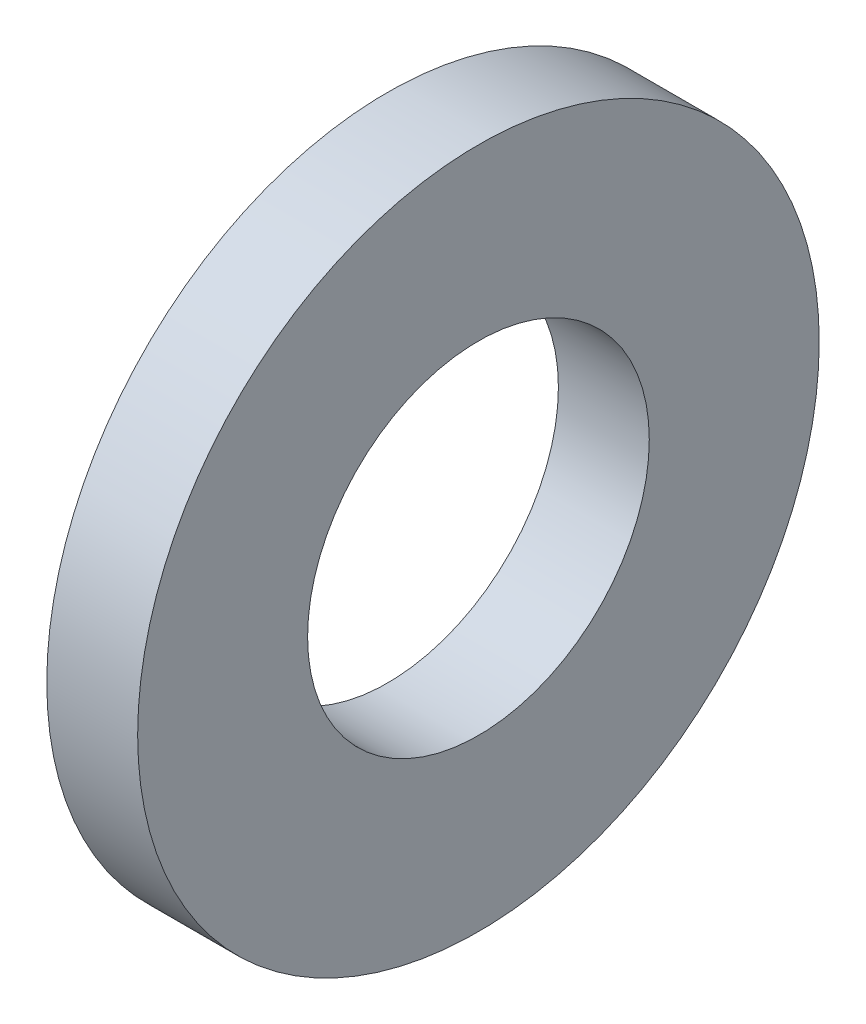
from build123d import *

# Parameters (mm, degrees)
SKETCH1_R           = 2.38125
SKETCH1_R_2         = 1.1938
BOSS_EXTRUDE1_DEPTH = 0.635


with BuildPart() as part:
    # Sketch1 → Boss-Extrude1 (new body)
    with BuildSketch(Plane(origin=(0, 0, 0), x_dir=(0, 0, -1), z_dir=(1, 0, 0))):
        Circle(SKETCH1_R)
        Circle(SKETCH1_R_2, mode=Mode.SUBTRACT)
    extrude(amount=BOSS_EXTRUDE1_DEPTH)


solid = part.part
